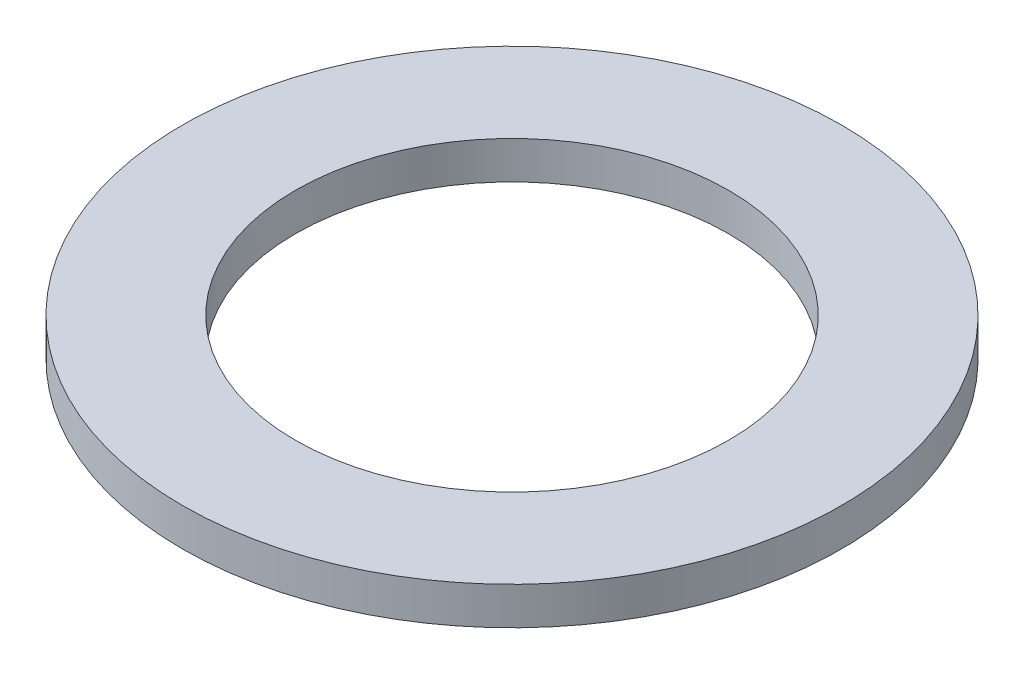
from build123d import *

# Parameters (mm, degrees)
SKETCH1_R           = 1.75
SKETCH1_R_2         = 1.15
BOSS_EXTRUDE1_DEPTH = 0.2


with BuildPart() as part:
    # Sketch1 → Boss-Extrude1 (new body)
    with BuildSketch(Plane(origin=(0, 0, 0), x_dir=(1, 0, 0), z_dir=(0, 1, 0))):
        Circle(SKETCH1_R)
        Circle(SKETCH1_R_2, mode=Mode.SUBTRACT)
    extrude(amount=BOSS_EXTRUDE1_DEPTH)


solid = part.part
